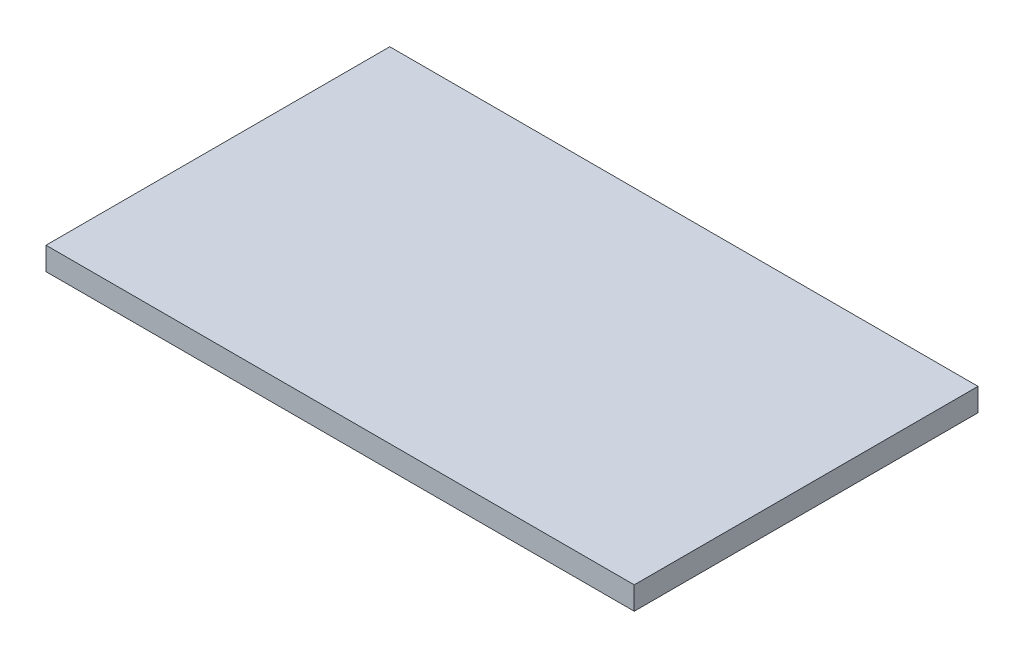
from build123d import *

# Parameters (mm, degrees)
SKETCH1_W           = 77
SKETCH1_H           = 45
BOSS_EXTRUDE1_DEPTH = 3


with BuildPart() as part:
    # Sketch1 → Boss-Extrude1 (new body)
    with BuildSketch(Plane(origin=(0, 0, 0), x_dir=(1, 0, 0), z_dir=(0, 1, 0))):
        with Locations((1.907185629, -4.929640719)):
            Rectangle(SKETCH1_W, SKETCH1_H)
    extrude(amount=BOSS_EXTRUDE1_DEPTH)


solid = part.part
